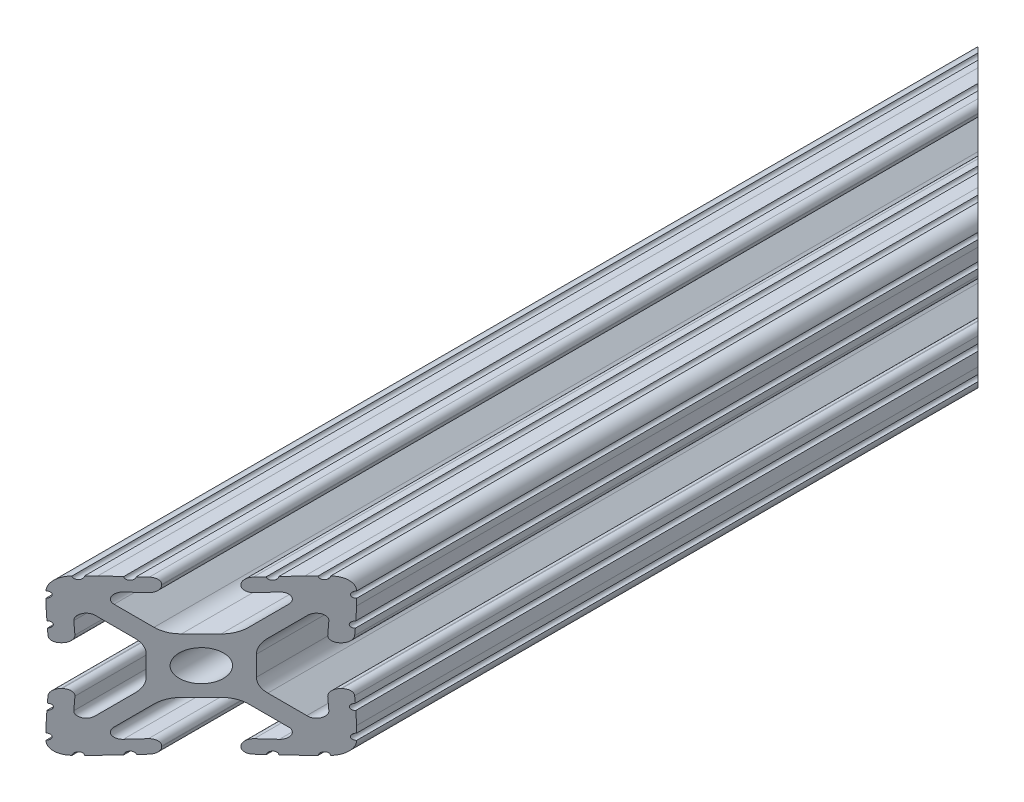
from build123d import *

# Parameters (mm, degrees)
SKETCH1_R          = 2.5527
EXTRUDE1_DEPTH     = 1219.2
SKETCH2_OUTSIDE_W  = 271.346
SKETCH2_OUTSIDE_H  = 1465.146
CUT_EXTRUDE2_DEPTH = 1220.730078446


with BuildPart() as part:
    # Sketch1 → Extrude1 (new body)
    with BuildSketch(Plane.XY):
        with BuildLine():
            Line((25.433443131, 2.149221002), (25.433433122, 2.132304602))
            ThreePointArc((25.433433122, 2.132304602), (24.81352977, 0.635652711), (23.316920529, 0.0156464))
            Line((23.316920529, 0.0156464), (23.300004129, 0.015621))
            ThreePointArc((23.300004129, 0.015621), (22.791978729, 0.518591735), (22.283953329, 0.015621))
            Line((22.283953329, 0.015621), (21.200262329, 0.015621))
            Line((21.200262329, 0.015621), (19.066357529, 0.0901446))
            ThreePointArc((19.066357529, 0.0901446), (18.57651791, 0.619499034), (18.050946389, 0.125602744))
            Line((18.050946389, 0.125602744), (16.985183129, 0.1812798))
            ThreePointArc((16.985183129, 0.1812798), (16.266656931, 0.501228728), (15.972027929, 1.230503))
            Line((15.972027929, 1.230503), (15.972002529, 1.330908925))
            ThreePointArc((15.972002529, 1.330908925), (16.292567692, 2.086113746), (17.058499831, 2.380127869))
            Line((17.058499831, 2.380127869), (19.115070367, 2.28984489))
            ThreePointArc((19.115070367, 2.28984489), (20.109237927, 2.946078438), (19.79674691, 4.095583101))
            Line((19.79674691, 4.095583101), (16.602495326, 7.289892083))
            ThreePointArc((16.602495326, 7.289892083), (15.5724442, 7.978160281), (14.357411125, 8.219848224))
            Line((14.357411125, 8.219848224), (12.733578665, 8.219848224))
            Line((12.733578665, 8.219848224), (11.109350265, 8.219848224))
            ThreePointArc((11.109350265, 8.219848224), (9.894326313, 7.97816406), (8.864280029, 7.289906048))
            Line((8.864280029, 7.289906048), (5.670118065, 4.095726424))
            ThreePointArc((5.670118065, 4.095726424), (5.357454926, 2.946), (6.351985959, 2.289846732))
            Line((6.351985959, 2.289846732), (8.408555268, 2.380129669))
            ThreePointArc((8.408555268, 2.380129669), (9.174487549, 2.086116104), (9.495053265, 1.330911592))
            Line((9.495053265, 1.330911592), (9.495078665, 1.230505007))
            ThreePointArc((9.495078665, 1.230505007), (9.200425317, 0.501212103), (8.481859988, 0.181286169))
            Line((8.481859988, 0.181286169), (7.416109406, 0.125604568))
            ThreePointArc((7.416109406, 0.125604568), (6.890689076, 0.615566134), (6.400728384, 0.090144989))
            Line((6.400728384, 0.090144989), (4.266844329, 0.015621))
            Line((4.266844329, 0.015621), (3.183051729, 0.015621))
            ThreePointArc((3.183051729, 0.015621), (2.675064429, 0.52002892), (2.167077129, 0.015621))
            Line((2.167077129, 0.015621), (2.150186129, 0.015621))
            ThreePointArc((2.150186129, 0.015621), (0.653473782, 0.635584814), (0.033527929, 2.1323046))
            Line((0.033527929, 2.1323046), (0.033502529, 2.149221))
            ThreePointArc((0.033502529, 2.149221), (0.541502529, 2.657221), (0.033502529, 3.165221))
            Line((0.033502529, 3.165221), (0.033502529, 4.2489628))
            Line((0.033502529, 4.2489628), (0.108051389, 6.382893005))
            ThreePointArc((0.108051389, 6.382893005), (0.636769546, 6.872740923), (0.143484067, 7.398253347))
            Line((0.143484067, 7.398253347), (0.199186453, 8.463965811))
            ThreePointArc((0.199186453, 8.463965811), (0.519108205, 9.182539461), (1.248405666, 9.47719728))
            Line((1.248405666, 9.47719728), (1.348815787, 9.477273486))
            ThreePointArc((1.348815787, 9.477273486), (2.104048619, 9.15668186), (2.398034533, 8.3907002))
            Line((2.398034533, 8.3907002), (2.307726292, 6.334129777))
            ThreePointArc((2.307726292, 6.334129777), (2.917959272, 5.36690304), (4.041530045, 5.580211665))
            Line((4.041530045, 5.580211665), (7.299319478, 8.838034664))
            ThreePointArc((7.299319478, 8.838034664), (7.987564527, 9.868074786), (8.229243882, 11.083087128))
            Line((8.229243882, 11.083087128), (8.229243882, 12.715595928))
            Line((8.229243882, 12.715595928), (8.229243882, 14.348182637))
            ThreePointArc((8.229243882, 14.348182637), (7.987566856, 15.563189358), (7.299328083, 16.593226497))
            Line((7.299328083, 16.593226497), (4.041535389, 19.85107773))
            ThreePointArc((4.041535389, 19.85107773), (2.917975571, 20.06439507), (2.307727974, 19.09718836))
            Line((2.307727974, 19.09718836), (2.398036312, 17.040593596))
            ThreePointArc((2.398036312, 17.040593596), (2.10402253, 16.274661146), (1.348817665, 15.954095654))
            Line((1.348817665, 15.954095654), (1.248411465, 15.954095654))
            ThreePointArc((1.248411465, 15.954095654), (0.519124814, 16.248743141), (0.199193406, 16.967297282))
            Line((0.199193406, 16.967297282), (0.14348581, 18.033064914))
            ThreePointArc((0.14348581, 18.033064914), (0.63344738, 18.558485131), (0.108026456, 19.048445943))
            Line((0.108026456, 19.048445943), (0.033502529, 21.1823554))
            Line((0.033502529, 21.1823554), (0.033502529, 22.2660972))
            ThreePointArc((0.033502529, 22.2660972), (0.545094609, 22.7740845), (0.033502529, 23.2820718))
            Line((0.033502529, 23.2820718), (0.033502529, 23.298997075))
            ThreePointArc((0.033502529, 23.298997075), (0.653448354, 24.795691433), (2.15013525, 25.415655275))
            Line((2.15013525, 25.415655275), (2.167093654, 25.415629946))
            ThreePointArc((2.167093654, 25.415629946), (2.675083099, 24.904039996), (3.183068254, 25.415634206))
            Line((3.183068254, 25.415634206), (4.266835454, 25.415634206))
            Line((4.266835454, 25.415634206), (6.400740254, 25.341136006))
            ThreePointArc((6.400740254, 25.341136006), (6.890804215, 24.818958649), (7.416100594, 25.305677862))
            Line((7.416100594, 25.305677862), (8.481838454, 25.250000806))
            ThreePointArc((8.481838454, 25.250000806), (9.200412021, 24.930079072), (9.495069854, 24.200781707))
            Line((9.495069854, 24.200781707), (9.495069854, 24.100371406))
            ThreePointArc((9.495069854, 24.100371406), (9.174504645, 23.345166815), (8.408572699, 23.051152732))
            Line((8.408572699, 23.051152732), (6.352002282, 23.141435707))
            ThreePointArc((6.352002282, 23.141435707), (5.384806579, 22.531184689), (5.598121123, 21.407631959))
            Line((5.598121123, 21.407631959), (7.697410254, 19.308356606))
            Line((7.697410254, 19.308356606), (8.864372763, 18.141401758))
            ThreePointArc((8.864372763, 18.141401758), (9.894414341, 17.453153646), (11.109429425, 17.211473156))
            Line((11.109429425, 17.211473156), (12.733581625, 17.211473156))
            Line((12.733581625, 17.211473156), (14.357534054, 17.211473156))
            ThreePointArc((14.357534054, 17.211473156), (15.572561508, 17.45315877), (16.60260965, 18.141420692))
            Line((16.60260965, 18.141420692), (19.796856475, 21.335700428))
            ThreePointArc((19.796856475, 21.335700428), (20.109338963, 22.485254296), (19.115085927, 23.141440475))
            Line((19.115085927, 23.141440475), (17.057348777, 23.051157558))
            ThreePointArc((17.057348777, 23.051157558), (16.291416105, 23.345171208), (15.970850487, 24.100376193))
            Line((15.970850487, 24.100376193), (15.970850487, 24.200756993))
            ThreePointArc((15.970850487, 24.200756993), (16.265496714, 24.930042339), (16.98404849, 25.249974926))
            Line((16.98404849, 25.249974926), (18.050937347, 25.305682649))
            ThreePointArc((18.050937347, 25.305682649), (18.576354433, 24.815720969), (19.066318594, 25.341135742))
            Line((19.066318594, 25.341135742), (21.200253454, 25.415634206))
            Line((21.200253454, 25.415634206), (22.283969854, 25.415634206))
            ThreePointArc((22.283969854, 25.415634206), (22.791957154, 24.904042126), (23.299944454, 25.415634206))
            Line((23.299944454, 25.415634206), (23.316930297, 25.415634206))
            ThreePointArc((23.316930297, 25.415634206), (24.813629353, 24.795683684), (25.433588497, 23.2989882))
            Line((25.433588497, 23.2989882), (25.433613897, 23.2820718))
            ThreePointArc((25.433613897, 23.2820718), (24.925618902, 22.774071644), (25.43361421, 22.2660718))
            Line((25.43361421, 22.2660718), (25.4336042, 21.1823554))
            Line((25.4336042, 21.1823554), (25.3590552, 19.048476))
            ThreePointArc((25.3590552, 19.048476), (24.826095097, 18.558846649), (25.323514364, 18.033149546))
            Line((25.323514364, 18.033149546), (25.267781506, 16.967386543))
            ThreePointArc((25.267781506, 16.967386543), (24.947855109, 16.248812971), (24.21855381, 15.954159797))
            ThreePointArc((24.21855381, 15.954159797), (23.396859234, 16.236195338), (23.068959156, 17.040687453))
            Line((23.068959156, 17.040687453), (23.159251265, 19.097257735))
            ThreePointArc((23.159251265, 19.097257735), (22.549002581, 20.064456727), (21.425448036, 19.851143506))
            Line((21.425448036, 19.851143506), (18.167765516, 16.593442973))
            ThreePointArc((18.167765516, 16.593442973), (17.479516557, 15.563400992), (17.237835752, 14.348385149))
            Line((17.237835752, 14.348385149), (17.237835752, 12.715636694))
            Line((17.237835752, 12.715636694), (17.237835752, 11.083127894))
            ThreePointArc((17.237835752, 11.083127894), (17.47952023, 9.868103183), (18.16777909, 8.838056496))
            Line((18.16777909, 8.838056496), (21.353523773, 5.652332724))
            ThreePointArc((21.353523773, 5.652332724), (22.503190772, 5.339700837), (23.159374985, 6.334132928))
            Line((23.159374985, 6.334132928), (23.069082951, 8.390722922))
            ThreePointArc((23.069082951, 8.390722922), (23.363090217, 9.15665763), (24.118292102, 9.477229556))
            Line((24.118292102, 9.477229556), (24.218677373, 9.477255408))
            ThreePointArc((24.218677373, 9.477255408), (24.94789253, 9.182528501), (25.267744306, 8.463978895))
            Line((25.267744306, 8.463978895), (25.323466772, 7.398253367))
            ThreePointArc((25.323466772, 7.398253367), (24.833515373, 6.872829664), (25.358933799, 6.382872606))
            Line((25.358933799, 6.382872606), (25.43344779, 4.248962801))
            Line((25.43344779, 4.248962801), (25.43343778, 3.165221001))
            ThreePointArc((25.43343778, 3.165221001), (24.925433088, 2.657218326), (25.433443131, 2.149221002))
        make_face()
        with Locations((12.7335534, 12.7156464)):
            Circle(SKETCH1_R, mode=Mode.SUBTRACT)
    extrude(amount=-EXTRUDE1_DEPTH)

    # Sketch2 outside → Cut-Extrude2 (cut, through all)
    with BuildSketch(Plane(origin=(0, 0, 0), x_dir=(1, 0, 0), z_dir=(0, 1, 0))):
        with Locations((12.734, 609.6)):
            Rectangle(SKETCH2_OUTSIDE_W, SKETCH2_OUTSIDE_H)
        Polygon((0, 0), (25.433588497, 25.422408678), (25.433588497, 126.988744029), (0.033502529, 152.4), align=None, mode=Mode.SUBTRACT)
    extrude(amount=CUT_EXTRUDE2_DEPTH, mode=Mode.SUBTRACT)


solid = part.part
